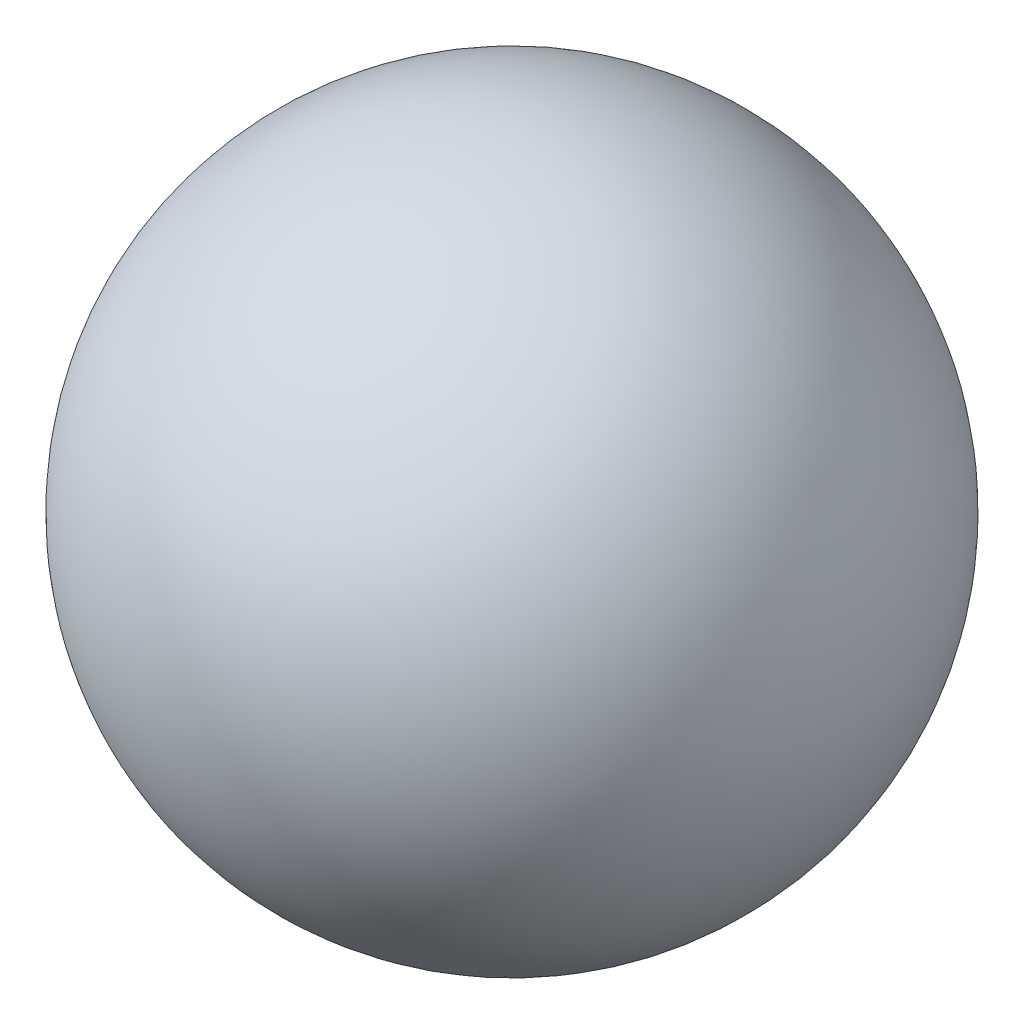
from build123d import *


with BuildPart() as part:
    # 草图1 one side → 旋转2 (revolve)
    with BuildSketch(Plane(origin=(0, 0, 0), x_dir=(1, 0, 0), z_dir=(0, 1, 0))):
        with BuildLine():
            ThreePointArc((0, -3.5), (2.474873734, -2.474873734), (3.5, 0))
            ThreePointArc((3.5, 0), (2.474873734, 2.474873734), (0, 3.5))
            Line((0, 3.5), (0, -3.5))
        make_face()
    revolve(axis=Axis((0, 0, -6.936103092), (0, 0, 1)))


solid = part.part
